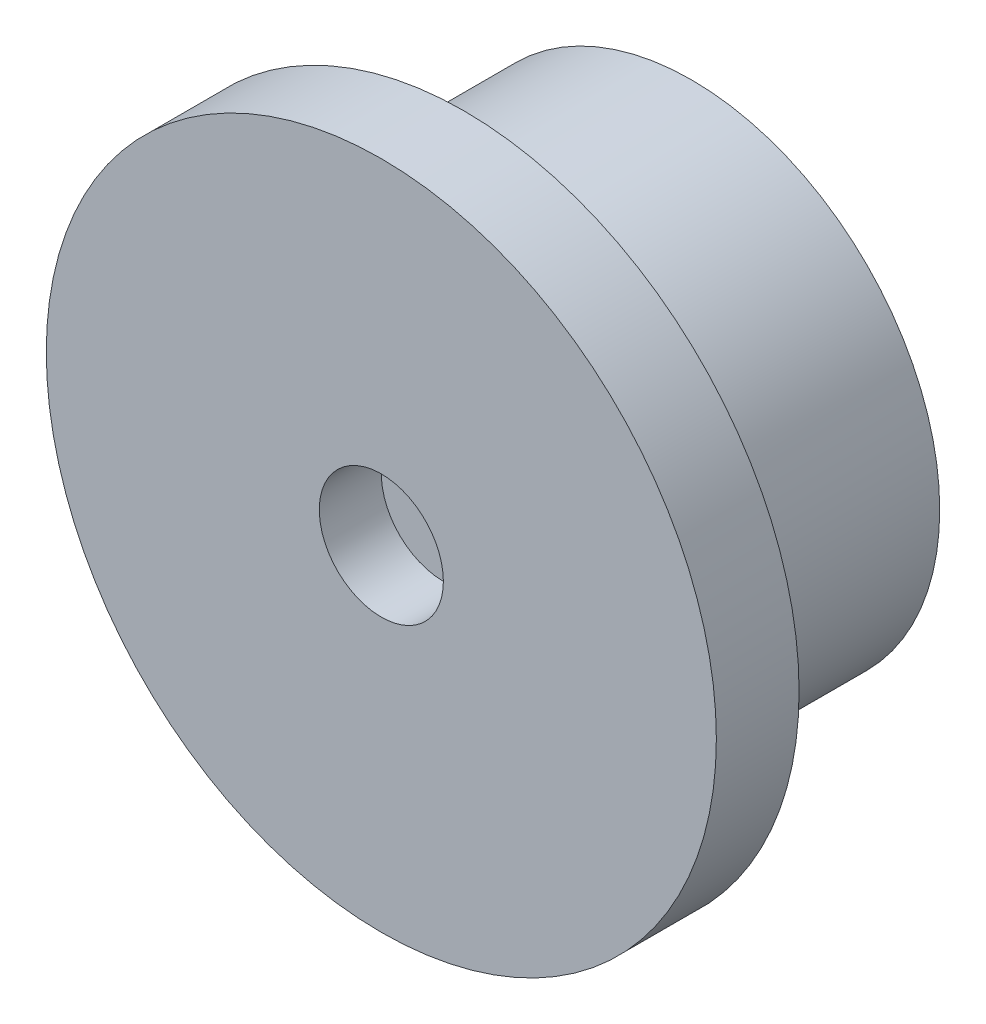
from build123d import *

# Parameters (mm, degrees)
SKIZZE1_R                       = 12
AUFSATZ_LINEAR_AUSTRAGEN1_DEPTH = 15
SKIZZE2_R                       = 16.2
AUFSATZ_LINEAR_AUSTRAGEN3_DEPTH = 4
SKIZZE3_R                       = 6
SCHNITT_LINEAR_AUSTRAGEN1_DEPTH = 3
FASE1_SIZE                      = 1.5
FASE1_SIZE2                     = 2.598076211
SKIZZE4_R                       = 1.1
SCHNITT_LINEAR_AUSTRAGEN2_DEPTH = 16
SKIZZE5_R                       = 3
SCHNITT_LINEAR_AUSTRAGEN3_DEPTH = 3


with BuildPart() as part:
    # Skizze1 → Aufsatz-Linear austragen1 (new body)
    with BuildSketch(Plane.XY):
        with Locations((0, -12)):
            Circle(SKIZZE1_R)
    extrude(amount=AUFSATZ_LINEAR_AUSTRAGEN1_DEPTH)

    # Skizze2 → Aufsatz-Linear austragen3 (add)
    with BuildSketch(Plane.XY.offset(15)):
        with Locations((0, -12)):
            Circle(SKIZZE2_R)
    extrude(amount=-AUFSATZ_LINEAR_AUSTRAGEN3_DEPTH)

    # Skizze3 → Schnitt-Linear austragen1 (cut)
    with BuildSketch(Plane.XY):
        with Locations((0, -12)):
            Circle(SKIZZE3_R)
    extrude(amount=SCHNITT_LINEAR_AUSTRAGEN1_DEPTH, mode=Mode.SUBTRACT)

    # Fase1
    fase1_edges = [part.edges().sort_by_distance(p)[0] for p in [
        (-6, -12, 3),
    ]]
    fase1_side = [part.faces().sort_by_distance(p)[0] for p in [
        (0, -12, 3),
    ]]
    chamfer(fase1_edges, length=FASE1_SIZE, length2=FASE1_SIZE2, reference=fase1_side[0])

    # Skizze4 → Schnitt-Linear austragen2 (cut, through all)
    with BuildSketch(Plane.XY.offset(15)):
        with Locations((0, -12)):
            Circle(SKIZZE4_R)
    extrude(amount=-SCHNITT_LINEAR_AUSTRAGEN2_DEPTH, mode=Mode.SUBTRACT)

    # Skizze5 → Schnitt-Linear austragen3 (cut)
    with BuildSketch(Plane.XY.offset(15)):
        with Locations((0, -12)):
            Circle(SKIZZE5_R)
    extrude(amount=-SCHNITT_LINEAR_AUSTRAGEN3_DEPTH, mode=Mode.SUBTRACT)


solid = part.part
